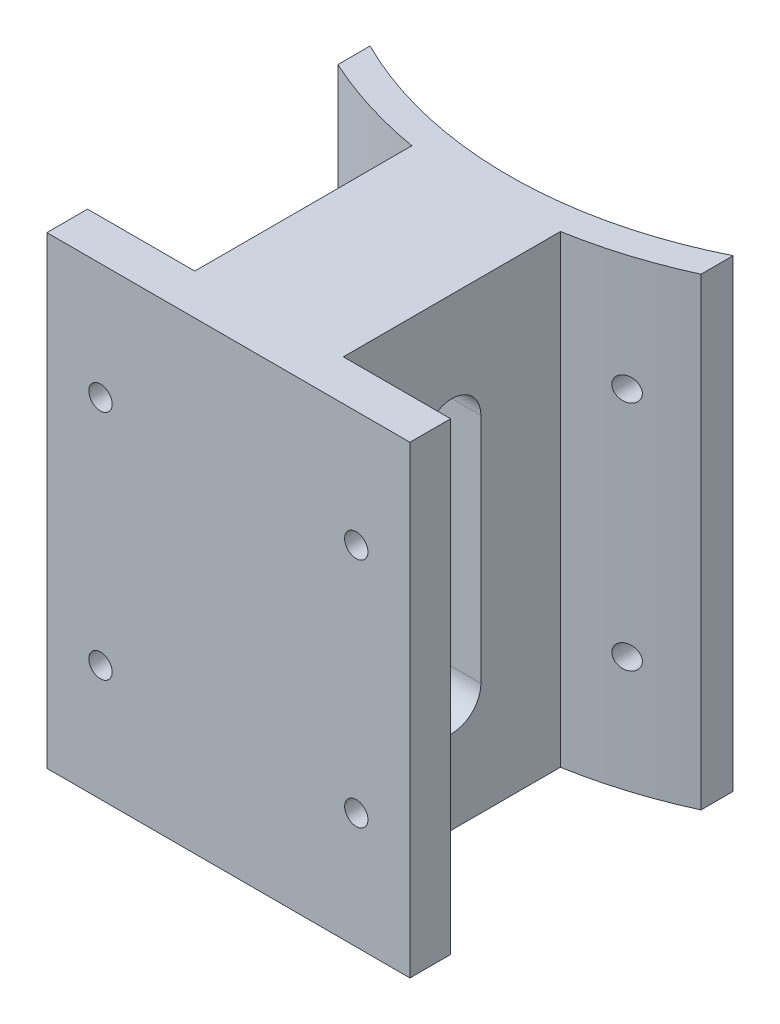
from build123d import *

# Parameters (mm, degrees)
BOSS_EXTRUDE1_DEPTH         = 101.6
CUT_EXTRUDE1_DEPTH          = 57.023894283
TAP_DRILL_FOR_1_4_20_TAP2_D = 5.1054


with BuildPart() as part:
    # Sketch1 → Boss-Extrude1 (new body)
    with BuildSketch(Plane(origin=(0, 0, 0), x_dir=(1, 0, 0), z_dir=(0, 1, 0))):
        with BuildLine():
            Line((-16.266605643, -141.378421793), (-39.75728864, -141.378421793))
            Line((-39.75728864, -141.378421793), (-39.75728864, -150.287727069))
            Line((-39.75728864, -150.287727069), (39.75728864, -150.287727069))
            Line((39.75728864, -150.287727069), (39.75728864, -141.378421793))
            Line((39.75728864, -141.378421793), (16.266605643, -141.378421793))
            Line((16.266605643, -141.378421793), (16.266605643, -93.850732767))
            ThreePointArc((16.266605643, -93.850732767), (28.248414097, -90.964771208), (39.75728864, -86.555880794))
            Line((39.75728864, -86.555880794), (39.75728864, -79.51457728))
            ThreePointArc((39.75728864, -79.51457728), (0, -88.9), (-39.75728864, -79.51457728))
            Line((-39.75728864, -79.51457728), (-39.75728864, -86.555880794))
            ThreePointArc((-39.75728864, -86.555880794), (-28.248414097, -90.964771208), (-16.266605643, -93.850732767))
            Line((-16.266605643, -93.850732767), (-16.266605643, -141.378421793))
        make_face()
    extrude(amount=BOSS_EXTRUDE1_DEPTH)

    # Sketch2 → Cut-Extrude1 (cut, through all)
    with BuildSketch(Plane(origin=(16.266605643, 0, 0), x_dir=(0, 0, -1), z_dir=(1, 0, 0))):
        with BuildLine():
            Line((-111.26457728, 75.434320996), (-111.26457728, 24.634320996))
            ThreePointArc((-111.26457728, 24.634320996), (-117.61457728, 18.284320996), (-123.96457728, 24.634320996))
            Line((-123.96457728, 24.634320996), (-123.96457728, 75.434320996))
            ThreePointArc((-123.96457728, 75.434320996), (-117.61457728, 81.784320996), (-111.26457728, 75.434320996))
        make_face()
    extrude(amount=-CUT_EXTRUDE1_DEPTH, mode=Mode.SUBTRACT)

    # Tap Drill for 1/4-20 Tap2 (through all)
    with Locations(Plane.XY.offset(150.287727069)):
        with Locations((28.011947142, 76.2), (-28.011947142, 76.2), (-28.011947142, 25.4), (28.011947142, 25.4)):
            Hole(TAP_DRILL_FOR_1_4_20_TAP2_D / 2)


solid = part.part
